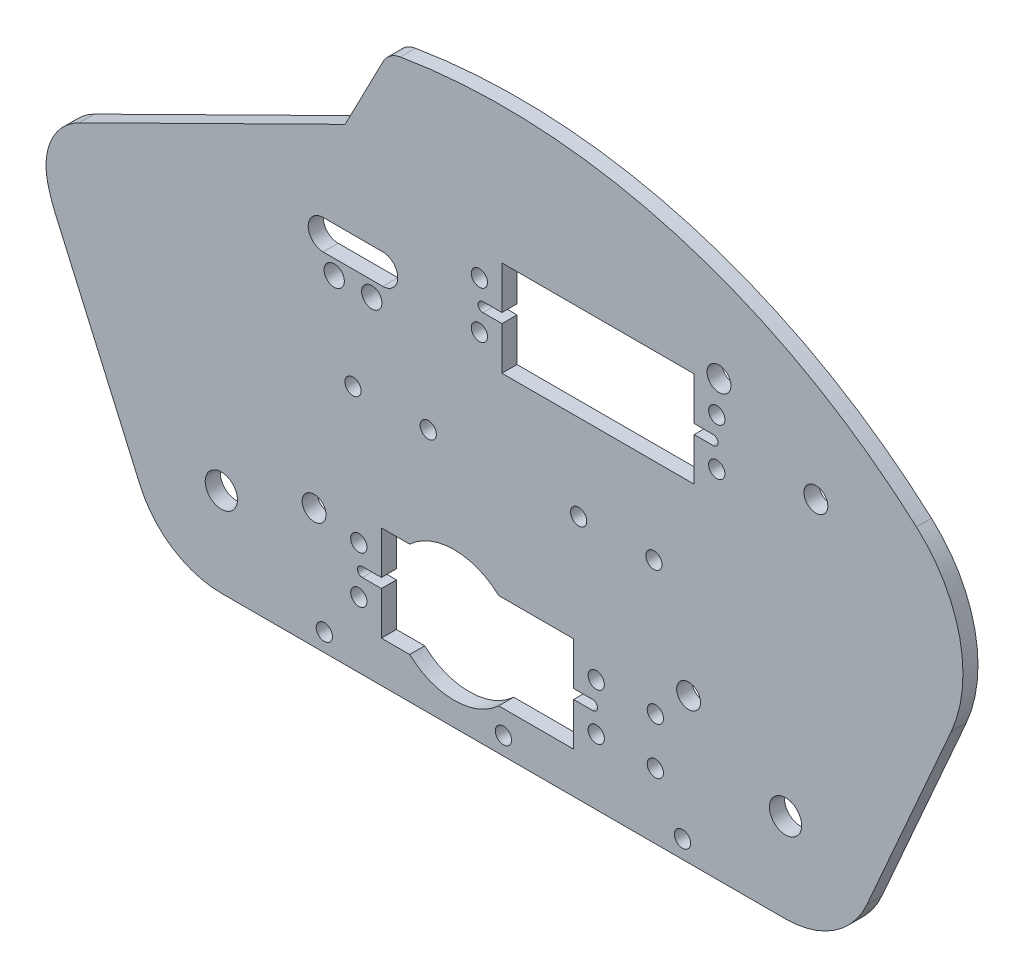
from build123d import *

# Parameters (mm, degrees)
SKETCH1_R           = 3.429
SKETCH1_R_2         = 2.54
BOSS_EXTRUDE1_DEPTH = 3.2004
SKETCH2_R           = 1.7272
CUT_EXTRUDE1_DEPTH  = 3.2004
SKETCH5_R           = 1.7272
SKETCH5_W           = 40.894
SKETCH5_H           = 20.32
CUT_EXTRUDE3_DEPTH  = 4.2004
CUT_EXTRUDE4_DEPTH  = 3.2004
SKETCH8_R           = 1.7272
CUT_EXTRUDE6_DEPTH  = 3.2004
SKETCH9_R           = 1.7272
SKETCH9_R_2         = 2.54
SKETCH9_W           = 40.894
SKETCH9_H           = 20.32
CUT_EXTRUDE8_DEPTH  = 3.2004
CUT_EXTRUDE9_DEPTH  = 3.2004
FILLET1_R           = 5.08
SKETCH11_R          = 2.159
CUT_EXTRUDE10_DEPTH = 3.2004
CUT_EXTRUDE11_DEPTH = 3.2004
SKETCH13_R          = 13.885201093
CUT_EXTRUDE12_DEPTH = 3.2004
SKETCH14_R          = 2.54
CUT_EXTRUDE13_DEPTH = 3.2004
CUT_EXTRUDE14_DEPTH = 3.2004
FILLET2_R           = 12.7


with BuildPart() as part:
    # Sketch1 → Boss-Extrude1 (new body)
    with BuildSketch(Plane.XY):
        with BuildLine():
            Line((0, 0), (120.015, 0))
            ThreePointArc((120.015, 0), (130.351788396, 3.075697789), (137.325636158, 11.302152592))
            Line((137.325636158, 11.302152592), (155.2575, 52.11572))
            ThreePointArc((155.2575, 52.11572), (157.08610336, 70.335755455), (147.862829504, 86.154880008))
            ThreePointArc((147.862829504, 86.154880008), (60.0075, 119.675648416), (-27.847829504, 86.154880008))
            ThreePointArc((-27.847829504, 86.154880008), (-37.07110336, 70.335755455), (-35.2425, 52.11572))
            Line((-35.2425, 52.11572), (-17.310636158, 11.302152592))
            ThreePointArc((-17.310636158, 11.302152592), (-10.336788396, 3.075697789), (0, 0))
        make_face()
        with Locations((120.015, 18.90776)):
            Circle(SKETCH1_R, mode=Mode.SUBTRACT)
        with Locations((0, 18.90776)):
            Circle(SKETCH1_R, mode=Mode.SUBTRACT)
        with Locations((19.734727626, 25.566426992)):
            Circle(SKETCH1_R_2, mode=Mode.SUBTRACT)
    extrude(amount=BOSS_EXTRUDE1_DEPTH)

    # Sketch2 → Cut-Extrude1 (cut)
    with BuildSketch(Plane(origin=(0, 0, 0), x_dir=(-1, 0, 0), z_dir=(0, 0, -1))):
        with Locations((-92.0115, 52.11572)):
            Circle(SKETCH2_R)
        with Locations((-76.0095, 52.11572)):
            Circle(SKETCH2_R)
        with Locations((-44.0055, 52.11572)):
            Circle(SKETCH2_R)
        with Locations((-28.0035, 52.11572)):
            Circle(SKETCH2_R)
    extrude(amount=-CUT_EXTRUDE1_DEPTH, mode=Mode.SUBTRACT)

    # Sketch5 → Cut-Extrude3 (cut, through all)
    with BuildSketch(Plane(origin=(0, 0, 0), x_dir=(-1, 0, 0), z_dir=(0, 0, -1))):
        with Locations((-79.746999972, 23.90776)):
            Circle(SKETCH5_R)
        with Locations((-29.246999972, 13.90776)):
            Circle(SKETCH5_R)
        with Locations((-29.246999972, 23.90776)):
            Circle(SKETCH5_R)
        with Locations((-79.746999972, 13.90776)):
            Circle(SKETCH5_R)
        with Locations((-92.322240346, 23.90776)):
            Circle(SKETCH5_R)
        with Locations((-92.322240346, 13.90776)):
            Circle(SKETCH5_R)
        with Locations((-54.496999972, 18.90776)):
            Rectangle(SKETCH5_W, SKETCH5_H)
    extrude(amount=-CUT_EXTRUDE3_DEPTH, mode=Mode.SUBTRACT)

    # Sketch6 → Cut-Extrude4 (cut)
    with BuildSketch(Plane.XY.offset(3.2004)):
        with BuildLine():
            Line((29.985999972, 19.92376), (34.049999972, 19.92376))
            Line((34.049999972, 19.92376), (34.049999972, 17.89176))
            Line((34.049999972, 17.89176), (29.985999972, 17.89176))
            ThreePointArc((29.985999972, 17.89176), (28.969999972, 18.90776), (29.985999972, 19.92376))
        make_face()
        with BuildLine():
            Line((74.943999972, 19.92376), (79.007999972, 19.92376))
            ThreePointArc((79.007999972, 19.92376), (80.023999972, 18.90776), (79.007999972, 17.89176))
            Line((79.007999972, 17.89176), (74.943999972, 17.89176))
            Line((74.943999972, 17.89176), (74.943999972, 19.92376))
        make_face()
    extrude(amount=-CUT_EXTRUDE4_DEPTH, mode=Mode.SUBTRACT)

    # Sketch8 → Cut-Extrude6 (cut)
    with BuildSketch(Plane.XY.offset(3.2004)):
        with Locations((21.9075, 3.81)):
            Circle(SKETCH8_R)
        with Locations((60.0075, 3.81)):
            Circle(SKETCH8_R)
        with Locations((98.1075, 3.81)):
            Circle(SKETCH8_R)
    extrude(amount=-CUT_EXTRUDE6_DEPTH, mode=Mode.SUBTRACT)

    # Sketch9 → Cut-Extrude8 (cut)
    with BuildSketch(Plane(origin=(0, 0, 0), x_dir=(-1, 0, 0), z_dir=(0, 0, -1))):
        with Locations((-105.391483991, 85.535782838)):
            Circle(SKETCH9_R)
        with Locations((-105.860285109, 92.437383775)):
            Circle(SKETCH9_R_2)
        with Locations((-54.891483991, 75.535782838)):
            Circle(SKETCH9_R)
        with Locations((-54.891483991, 85.535782838)):
            Circle(SKETCH9_R)
        with Locations((-105.391483991, 75.535782838)):
            Circle(SKETCH9_R)
        with Locations((-126.474462623, 80.535782838)):
            Circle(SKETCH9_R_2)
        with Locations((-80.141483991, 80.535782838)):
            Rectangle(SKETCH9_W, SKETCH9_H)
    extrude(amount=-CUT_EXTRUDE8_DEPTH, mode=Mode.SUBTRACT)

    # Sketch10 → Cut-Extrude9 (cut)
    with BuildSketch(Plane.XY.offset(3.2004)):
        with BuildLine():
            Line((-24.96979716, 88.651483667), (-19.207398738, 77.007598217))
            Line((-19.207398738, 77.007598217), (26.33351958, 99.545171003))
            Line((26.33351958, 99.545171003), (35.569015789, 117.391739689))
            ThreePointArc((35.569015789, 117.391739689), (3.443784755, 106.930742334), (-24.96979716, 88.651483667))
        make_face()
    extrude(amount=-CUT_EXTRUDE9_DEPTH, mode=Mode.SUBTRACT)

    # Fillet1
    fillet1_edges = [part.edges().sort_by_distance(p)[0] for p in [
        (35.569015789, 117.391739689, 1.6002),
        (-24.96979716, 88.651483667, 1.6002),
    ]]
    fillet(fillet1_edges, radius=FILLET1_R)

    # Sketch11 → Cut-Extrude10 (cut)
    with BuildSketch(Plane(origin=(0, 0, 0), x_dir=(-1, 0, 0), z_dir=(0, 0, -1))):
        with Locations((-32.004, 70.53072)):
            Circle(SKETCH11_R)
        with Locations((-24.003, 70.53072)):
            Circle(SKETCH11_R)
        with BuildLine():
            Line((-34.3535, 80.05572), (-21.6535, 80.05572))
            ThreePointArc((-21.6535, 80.05572), (-18.4785, 76.88072), (-21.6535, 73.70572))
            Line((-21.6535, 73.70572), (-34.3535, 73.70572))
            ThreePointArc((-34.3535, 73.70572), (-37.5285, 76.88072), (-34.3535, 80.05572))
        make_face()
    extrude(amount=-CUT_EXTRUDE10_DEPTH, mode=Mode.SUBTRACT)

    # Sketch12 → Cut-Extrude11 (cut)
    with BuildSketch(Plane(origin=(0, 0, 0), x_dir=(-1, 0, 0), z_dir=(0, 0, -1))):
        with BuildLine():
            Line((-104.652483991, 81.551782838), (-100.588483991, 81.551782838))
            Line((-100.588483991, 81.551782838), (-100.588483991, 79.519782838))
            Line((-100.588483991, 79.519782838), (-104.652483991, 79.519782838))
            ThreePointArc((-104.652483991, 79.519782838), (-105.668483991, 80.535782838), (-104.652483991, 81.551782838))
        make_face()
        with BuildLine():
            Line((-59.694483991, 81.551782838), (-55.630483991, 81.551782838))
            ThreePointArc((-55.630483991, 81.551782838), (-54.614483991, 80.535782838), (-55.630483991, 79.519782838))
            Line((-55.630483991, 79.519782838), (-59.694483991, 79.519782838))
            Line((-59.694483991, 79.519782838), (-59.694483991, 81.551782838))
        make_face()
    extrude(amount=-CUT_EXTRUDE11_DEPTH, mode=Mode.SUBTRACT)

    # Sketch13 → Cut-Extrude12 (cut)
    with BuildSketch(Plane(origin=(0, 0, 0), x_dir=(-1, 0, 0), z_dir=(0, 0, -1))):
        with Locations((-49.53, 18.90776)):
            Circle(SKETCH13_R)
    extrude(amount=-CUT_EXTRUDE12_DEPTH, mode=Mode.SUBTRACT)

    # Sketch14 → Cut-Extrude13 (cut)
    with BuildSketch(Plane(origin=(0, 0, 0), x_dir=(-1, 0, 0), z_dir=(0, 0, -1))):
        with Locations((-99.400822485, 30.809360937)):
            Circle(SKETCH14_R)
    extrude(amount=-CUT_EXTRUDE13_DEPTH, mode=Mode.SUBTRACT)

    # Sketch15 → Cut-Extrude14 (cut)
    with BuildSketch(Plane(origin=(0, 0, 0), x_dir=(-1, 0, 0), z_dir=(0, 0, -1))):
        Polygon((33.771104783, 106.435991135), (93.302614335, 68.041010777), (77.912627241, 47.955189764), (19.207398738, 77.007598217), align=None)
    extrude(amount=-CUT_EXTRUDE14_DEPTH, mode=Mode.SUBTRACT)

    # Fillet2
    fillet2_edges = [part.edges().sort_by_distance(p)[0] for p in [
        (-37.48662973, 67.961458741, 1.6002),
    ]]
    fillet(fillet2_edges, radius=FILLET2_R)


solid = part.part
